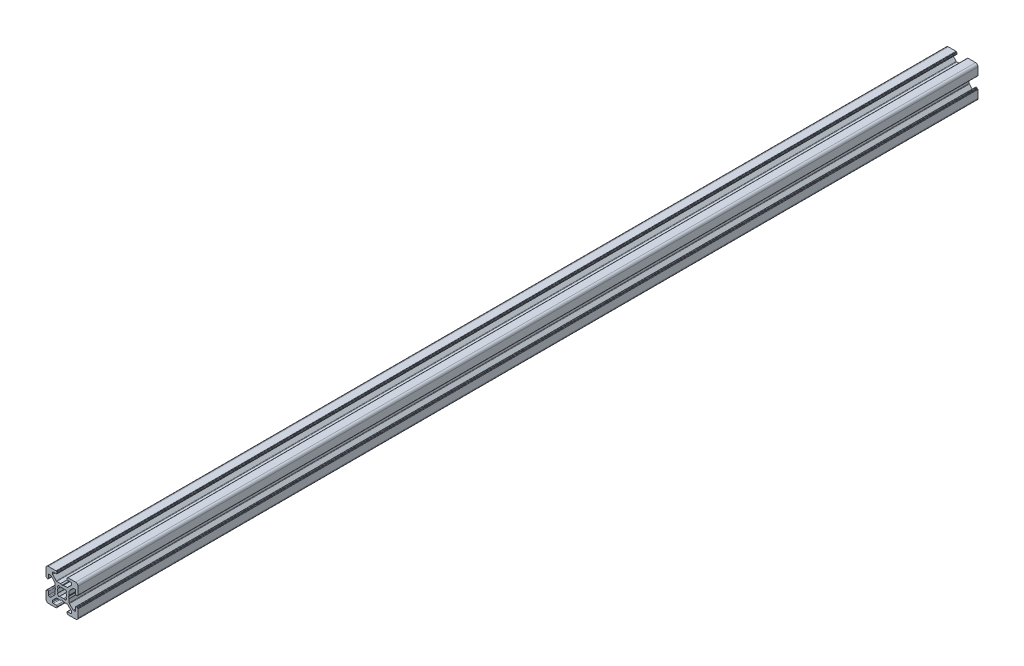
from build123d import *

# Parameters (mm, degrees)
EXTRUDE1_DEPTH = 561.63


with BuildPart() as part:
    # Sketch1 → Extrude1 (new body)
    with BuildSketch(Plane.XY):
        with BuildLine():
            Line((-3.5, 8.499999673), (-5.500000686, 8.499999673))
            ThreePointArc((-5.500000686, 8.499999673), (-5.853554077, 8.353553064), (-6.000000686, 7.999999673))
            Line((-6.000000686, 7.999999673), (-6.000000686, 7.267766626))
            ThreePointArc((-6.000000686, 7.267766626), (-5.961940448, 7.076424899), (-5.853554059, 6.914213219))
            Line((-5.853554059, 6.914213219), (-3.585787212, 4.646446592))
            ThreePointArc((-3.585787212, 4.646446592), (-3.423575544, 4.538060229), (-3.232233839, 4.5))
            Line((-3.232233839, 4.5), (-0.953590312, 4.5))
            ThreePointArc((-0.953590312, 4.5), (-0.901826505, 4.493185166), (-0.853590316, 4.473205083))
            Line((-0.853590316, 4.473205083), (-0.100000045, 4.038119562))
            ThreePointArc((-0.100000045, 4.038119562), (0, 4.011324632), (0.100000045, 4.038119562))
            Line((0.100000045, 4.038119562), (0.853590316, 4.473205083))
            ThreePointArc((0.853590316, 4.473205083), (0.901826505, 4.493185166), (0.953590312, 4.5))
            Line((0.953590312, 4.5), (3.232233839, 4.5))
            ThreePointArc((3.232233839, 4.5), (3.423575544, 4.538060229), (3.585787212, 4.646446592))
            Line((3.585787212, 4.646446592), (5.853554059, 6.914213219))
            ThreePointArc((5.853554059, 6.914213219), (5.961940448, 7.076424899), (6.000000686, 7.267766626))
            Line((6.000000686, 7.267766626), (6.000000686, 7.999999673))
            ThreePointArc((6.000000686, 7.999999673), (5.853554077, 8.353553064), (5.500000686, 8.499999673))
            Line((5.500000686, 8.499999673), (3.5, 8.499999673))
            ThreePointArc((3.5, 8.499999673), (3.146446609, 8.646446283), (3, 8.999999673))
            Line((3, 8.999999673), (3, 9.3))
            ThreePointArc((3, 9.3), (3.058578644, 9.441421356), (3.2, 9.5))
            Line((3.2, 9.5), (3.350000228, 9.5))
            ThreePointArc((3.350000228, 9.5), (3.491421584, 9.558578644), (3.550000228, 9.7))
            Line((3.550000228, 9.7), (3.550000228, 9.8))
            ThreePointArc((3.550000228, 9.8), (3.608578871, 9.941421356), (3.750000228, 10))
            Line((3.750000228, 10), (8.5, 10))
            ThreePointArc((8.5, 10), (9.560660172, 9.560660172), (10, 8.5))
            Line((10, 8.5), (10, 3.749999605))
            ThreePointArc((10, 3.749999605), (9.941421356, 3.608578248), (9.8, 3.549999605))
            Line((9.8, 3.549999605), (9.699999732, 3.549999605))
            ThreePointArc((9.699999732, 3.549999605), (9.558578376, 3.491420961), (9.499999732, 3.349999605))
            Line((9.499999732, 3.349999605), (9.499999732, 3.2))
            ThreePointArc((9.499999732, 3.2), (9.441421088, 3.058578644), (9.299999732, 3))
            Line((9.299999732, 3), (8.999999732, 3))
            ThreePointArc((8.999999732, 3), (8.646446341, 3.146446609), (8.499999732, 3.5))
            Line((8.499999732, 3.5), (8.499999732, 5.499999605))
            ThreePointArc((8.499999732, 5.499999605), (8.353553123, 5.853552995), (7.999999732, 5.999999605))
            Line((7.999999732, 5.999999605), (7.267766685, 5.999999605))
            ThreePointArc((7.267766685, 5.999999605), (7.076424969, 5.961939371), (6.914213294, 5.853552995))
            Line((6.914213294, 5.853552995), (4.646446398, 3.585786099))
            ThreePointArc((4.646446398, 3.585786099), (4.538060023, 3.423574425), (4.499999789, 3.232232708))
            Line((4.499999789, 3.232232708), (4.499999789, 0.953589302))
            ThreePointArc((4.499999789, 0.953589302), (4.493184953, 0.90182549), (4.473204867, 0.853589297))
            Line((4.473204867, 0.853589297), (4.038119841, 0.099999969))
            ThreePointArc((4.038119841, 0.099999969), (4.011324929, 0), (4.038119841, -0.099999969))
            Line((4.038119841, -0.099999969), (4.473204867, -0.853589297))
            ThreePointArc((4.473204867, -0.853589297), (4.493184953, -0.90182549), (4.499999789, -0.953589302))
            Line((4.499999789, -0.953589302), (4.499999789, -3.232232708))
            ThreePointArc((4.499999789, -3.232232708), (4.538060023, -3.423574425), (4.646446398, -3.585786099))
            Line((4.646446398, -3.585786099), (6.914213294, -5.853552995))
            ThreePointArc((6.914213294, -5.853552995), (7.076424969, -5.961939371), (7.267766685, -5.999999605))
            Line((7.267766685, -5.999999605), (7.999999732, -5.999999605))
            ThreePointArc((7.999999732, -5.999999605), (8.353553123, -5.853552995), (8.499999732, -5.499999605))
            Line((8.499999732, -5.499999605), (8.499999732, -3.5))
            ThreePointArc((8.499999732, -3.5), (8.646446341, -3.146446609), (8.999999732, -3))
            Line((8.999999732, -3), (9.299999732, -3))
            ThreePointArc((9.299999732, -3), (9.441421088, -3.058578644), (9.499999732, -3.2))
            Line((9.499999732, -3.2), (9.499999732, -3.349999605))
            ThreePointArc((9.499999732, -3.349999605), (9.558578376, -3.491420961), (9.699999732, -3.549999605))
            Line((9.699999732, -3.549999605), (9.8, -3.549999605))
            ThreePointArc((9.8, -3.549999605), (9.941421356, -3.608578248), (10, -3.749999605))
            Line((10, -3.749999605), (10, -8.5))
            ThreePointArc((10, -8.5), (9.560660172, -9.560660172), (8.5, -10))
            Line((8.5, -10), (3.750000228, -10))
            ThreePointArc((3.750000228, -10), (3.608578871, -9.941421356), (3.550000228, -9.8))
            Line((3.550000228, -9.8), (3.550000228, -9.7))
            ThreePointArc((3.550000228, -9.7), (3.491421584, -9.558578644), (3.350000228, -9.5))
            Line((3.350000228, -9.5), (3.2, -9.5))
            ThreePointArc((3.2, -9.5), (3.058578644, -9.441421356), (3, -9.3))
            Line((3, -9.3), (3, -8.999999673))
            ThreePointArc((3, -8.999999673), (3.146446609, -8.646446283), (3.5, -8.499999673))
            Line((3.5, -8.499999673), (5.500000686, -8.499999673))
            ThreePointArc((5.500000686, -8.499999673), (5.853554077, -8.353553064), (6.000000686, -7.999999673))
            Line((6.000000686, -7.999999673), (6.000000686, -7.267766626))
            ThreePointArc((6.000000686, -7.267766626), (5.961940448, -7.076424899), (5.853554059, -6.914213219))
            Line((5.853554059, -6.914213219), (3.585787212, -4.646446592))
            ThreePointArc((3.585787212, -4.646446592), (3.423575544, -4.538060229), (3.232233839, -4.5))
            Line((3.232233839, -4.5), (0.953590312, -4.5))
            ThreePointArc((0.953590312, -4.5), (0.901826505, -4.493185166), (0.853590316, -4.473205083))
            Line((0.853590316, -4.473205083), (0.100000045, -4.038119562))
            ThreePointArc((0.100000045, -4.038119562), (0, -4.011324632), (-0.100000045, -4.038119562))
            Line((-0.100000045, -4.038119562), (-0.853590316, -4.473205083))
            ThreePointArc((-0.853590316, -4.473205083), (-0.901826505, -4.493185166), (-0.953590312, -4.5))
            Line((-0.953590312, -4.5), (-3.232233839, -4.5))
            ThreePointArc((-3.232233839, -4.5), (-3.423575544, -4.538060229), (-3.585787212, -4.646446592))
            Line((-3.585787212, -4.646446592), (-5.853554059, -6.914213219))
            ThreePointArc((-5.853554059, -6.914213219), (-5.961940448, -7.076424899), (-6.000000686, -7.267766626))
            Line((-6.000000686, -7.267766626), (-6.000000686, -7.999999673))
            ThreePointArc((-6.000000686, -7.999999673), (-5.853554077, -8.353553064), (-5.500000686, -8.499999673))
            Line((-5.500000686, -8.499999673), (-3.5, -8.499999673))
            ThreePointArc((-3.5, -8.499999673), (-3.146446609, -8.646446283), (-3, -8.999999673))
            Line((-3, -8.999999673), (-3, -9.3))
            ThreePointArc((-3, -9.3), (-3.058578644, -9.441421356), (-3.2, -9.5))
            Line((-3.2, -9.5), (-3.350000228, -9.5))
            ThreePointArc((-3.350000228, -9.5), (-3.491421584, -9.558578644), (-3.550000228, -9.7))
            Line((-3.550000228, -9.7), (-3.550000228, -9.8))
            ThreePointArc((-3.550000228, -9.8), (-3.608578871, -9.941421356), (-3.750000228, -10))
            Line((-3.750000228, -10), (-8.5, -10))
            ThreePointArc((-8.5, -10), (-9.560660172, -9.560660172), (-10, -8.5))
            Line((-10, -8.5), (-10, -3.749999605))
            ThreePointArc((-10, -3.749999605), (-9.941421356, -3.608578248), (-9.8, -3.549999605))
            Line((-9.8, -3.549999605), (-9.699999732, -3.549999605))
            ThreePointArc((-9.699999732, -3.549999605), (-9.558578376, -3.491420961), (-9.499999732, -3.349999605))
            Line((-9.499999732, -3.349999605), (-9.499999732, -3.2))
            ThreePointArc((-9.499999732, -3.2), (-9.441421088, -3.058578644), (-9.299999732, -3))
            Line((-9.299999732, -3), (-8.999999732, -3))
            ThreePointArc((-8.999999732, -3), (-8.646446341, -3.146446609), (-8.499999732, -3.5))
            Line((-8.499999732, -3.5), (-8.499999732, -5.499999605))
            ThreePointArc((-8.499999732, -5.499999605), (-8.353553123, -5.853552995), (-7.999999732, -5.999999605))
            Line((-7.999999732, -5.999999605), (-7.267766685, -5.999999605))
            ThreePointArc((-7.267766685, -5.999999605), (-7.076424969, -5.961939371), (-6.914213294, -5.853552995))
            Line((-6.914213294, -5.853552995), (-4.646446398, -3.585786099))
            ThreePointArc((-4.646446398, -3.585786099), (-4.538060023, -3.423574425), (-4.499999789, -3.232232708))
            Line((-4.499999789, -3.232232708), (-4.499999789, -0.953589302))
            ThreePointArc((-4.499999789, -0.953589302), (-4.493184953, -0.90182549), (-4.473204867, -0.853589297))
            Line((-4.473204867, -0.853589297), (-4.038119841, -0.099999969))
            ThreePointArc((-4.038119841, -0.099999969), (-4.011324929, 0), (-4.038119841, 0.099999969))
            Line((-4.038119841, 0.099999969), (-4.473204867, 0.853589297))
            ThreePointArc((-4.473204867, 0.853589297), (-4.493184953, 0.90182549), (-4.499999789, 0.953589302))
            Line((-4.499999789, 0.953589302), (-4.499999789, 3.232232708))
            ThreePointArc((-4.499999789, 3.232232708), (-4.538060023, 3.423574425), (-4.646446398, 3.585786099))
            Line((-4.646446398, 3.585786099), (-6.914213294, 5.853552995))
            ThreePointArc((-6.914213294, 5.853552995), (-7.076424969, 5.961939371), (-7.267766685, 5.999999605))
            Line((-7.267766685, 5.999999605), (-7.999999732, 5.999999605))
            ThreePointArc((-7.999999732, 5.999999605), (-8.353553123, 5.853552995), (-8.499999732, 5.499999605))
            Line((-8.499999732, 5.499999605), (-8.499999732, 3.5))
            ThreePointArc((-8.499999732, 3.5), (-8.646446341, 3.146446609), (-8.999999732, 3))
            Line((-8.999999732, 3), (-9.299999732, 3))
            ThreePointArc((-9.299999732, 3), (-9.441421088, 3.058578644), (-9.499999732, 3.2))
            Line((-9.499999732, 3.2), (-9.499999732, 3.349999605))
            ThreePointArc((-9.499999732, 3.349999605), (-9.558578376, 3.491420961), (-9.699999732, 3.549999605))
            Line((-9.699999732, 3.549999605), (-9.8, 3.549999605))
            ThreePointArc((-9.8, 3.549999605), (-9.941421356, 3.608578248), (-10, 3.749999605))
            Line((-10, 3.749999605), (-10, 8.5))
            ThreePointArc((-10, 8.5), (-9.560660172, 9.560660172), (-8.5, 10))
            Line((-8.5, 10), (-3.750000228, 10))
            ThreePointArc((-3.750000228, 10), (-3.608578871, 9.941421356), (-3.550000228, 9.8))
            Line((-3.550000228, 9.8), (-3.550000228, 9.7))
            ThreePointArc((-3.550000228, 9.7), (-3.491421584, 9.558578644), (-3.350000228, 9.5))
            Line((-3.350000228, 9.5), (-3.2, 9.5))
            ThreePointArc((-3.2, 9.5), (-3.058578644, 9.441421356), (-3, 9.3))
            Line((-3, 9.3), (-3, 8.999999673))
            ThreePointArc((-3, 8.999999673), (-3.146446609, 8.646446283), (-3.5, 8.499999673))
        make_face()
        with BuildLine():
            Line((-1.258185436, 2.445295362), (-1.91389502, 2.989640962))
            ThreePointArc((-1.91389502, 2.989640962), (-2.511737261, 2.508410485), (-2.992174953, 1.909930962))
            Line((-2.992174953, 1.909930962), (-2.445295423, 1.258185317))
            ThreePointArc((-2.445295423, 1.258185317), (-2.75, 0), (-2.445295423, -1.258185317))
            Line((-2.445295423, -1.258185317), (-2.992174953, -1.909930962))
            ThreePointArc((-2.992174953, -1.909930962), (-2.511737261, -2.508410485), (-1.91389502, -2.989640962))
            Line((-1.91389502, -2.989640962), (-1.258185436, -2.445295362))
            ThreePointArc((-1.258185436, -2.445295362), (0, -2.75), (1.258185436, -2.445295362))
            Line((1.258185436, -2.445295362), (1.91389502, -2.989640962))
            ThreePointArc((1.91389502, -2.989640962), (2.511737261, -2.508410485), (2.992174953, -1.909930962))
            Line((2.992174953, -1.909930962), (2.445295423, -1.258185317))
            ThreePointArc((2.445295423, -1.258185317), (2.75, 0), (2.445295423, 1.258185317))
            Line((2.445295423, 1.258185317), (2.992174953, 1.909930962))
            ThreePointArc((2.992174953, 1.909930962), (2.511737261, 2.508410485), (1.91389502, 2.989640962))
            Line((1.91389502, 2.989640962), (1.258185436, 2.445295362))
            ThreePointArc((1.258185436, 2.445295362), (0, 2.75), (-1.258185436, 2.445295362))
        make_face(mode=Mode.SUBTRACT)
    extrude(amount=EXTRUDE1_DEPTH)


solid = part.part
